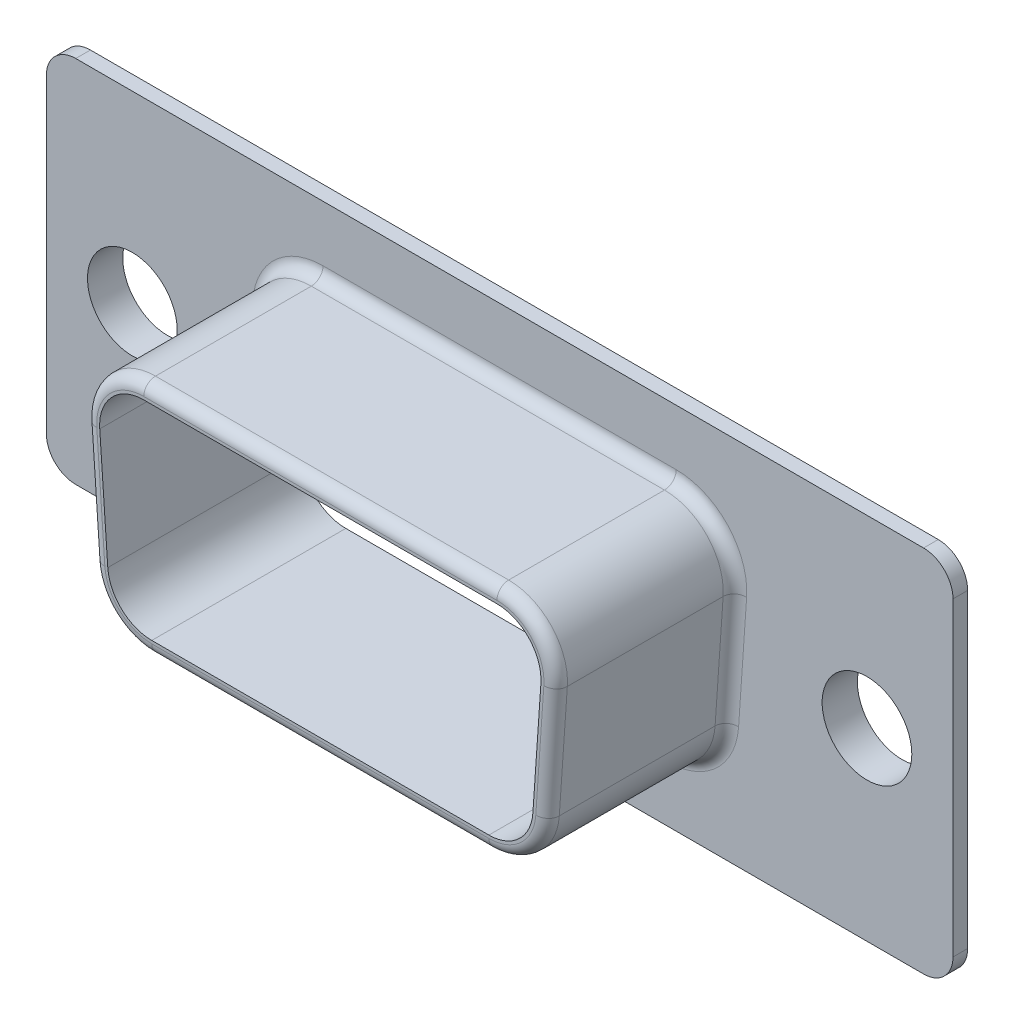
from build123d import *

# Parameters (mm, degrees)
BOSS_EXTRUDE1_DEPTH = 0.5
SKETCH2_R           = 1.525
CUT_EXTRUDE1_DEPTH  = 0.5
BOSS_EXTRUDE2_DEPTH = 6.1
SKETCH9_R           = 1.825
SKETCH9_R_2         = 1.525
BOSS_EXTRUDE3_DEPTH = 0.5
SKETCH10_R          = 2.025
SKETCH10_R_2        = 1.525
BOSS_EXTRUDE4_DEPTH = 0.2
CUT_EXTRUDE2_DEPTH  = 6.6
FILLET1_R           = 0.4
FILLET2_R           = 0.4


with BuildPart() as part:
    # Sketch1 → Boss-Extrude1 (new body)
    with BuildSketch(Plane.XY):
        with BuildLine():
            Line((-14.42, 6.275), (14.42, 6.275))
            ThreePointArc((14.42, 6.275), (15.127106781, 5.982106781), (15.42, 5.275))
            Line((15.42, 5.275), (15.42, -5.275))
            ThreePointArc((15.42, -5.275), (15.127106781, -5.982106781), (14.42, -6.275))
            Line((14.42, -6.275), (-14.42, -6.275))
            ThreePointArc((-14.42, -6.275), (-15.127106781, -5.982106781), (-15.42, -5.275))
            Line((-15.42, -5.275), (-15.42, 5.275))
            ThreePointArc((-15.42, 5.275), (-15.127106781, 5.982106781), (-14.42, 6.275))
        make_face()
    extrude(amount=BOSS_EXTRUDE1_DEPTH)

    # Sketch2 → Cut-Extrude1 (cut)
    with BuildSketch(Plane.XY.offset(0.5)):
        with Locations((-12.495, 0)):
            Circle(SKETCH2_R)
        with Locations((12.495, 0)):
            Circle(SKETCH2_R)
    extrude(amount=-CUT_EXTRUDE1_DEPTH, mode=Mode.SUBTRACT)

    # Sketch3 → Boss-Extrude2 (add)
    with BuildSketch(Plane.XY.offset(0.5)):
        with BuildLine():
            Line((-6.00685473, 3.975), (6.00685473, 3.975))
            ThreePointArc((6.00685473, 3.975), (7.469056783, 3.339538441), (8.00208564, 1.836965157))
            Line((8.00208564, 1.836965157), (7.7288152, -2.113034843))
            ThreePointArc((7.7288152, -2.113034843), (7.098122731, -3.437202053), (5.73358429, -3.975))
            Line((5.73358429, -3.975), (-5.73358429, -3.975))
            ThreePointArc((-5.73358429, -3.975), (-7.098122731, -3.437202053), (-7.7288152, -2.113034843))
            Line((-7.7288152, -2.113034843), (-8.00208564, 1.836965157))
            ThreePointArc((-8.00208564, 1.836965157), (-7.469056783, 3.339538441), (-6.00685473, 3.975))
        make_face()
    extrude(amount=BOSS_EXTRUDE2_DEPTH)

    # Sketch9 → Boss-Extrude3 (add)
    with BuildSketch(Plane(origin=(0, 0, 0), x_dir=(-1, 0, 0), z_dir=(0, 0, -1))):
        with Locations((-12.495, 0)):
            Circle(SKETCH9_R)
        with Locations(Location((-12.495, 0, 0), (0, 0, 180))):
            Circle(SKETCH9_R_2, mode=Mode.SUBTRACT)
        with Locations((12.495, 0)):
            Circle(SKETCH9_R)
        with Locations(Location((12.495, 0, 0), (0, 0, 180))):
            Circle(SKETCH9_R_2, mode=Mode.SUBTRACT)
    extrude(amount=BOSS_EXTRUDE3_DEPTH)

    # Sketch10 → Boss-Extrude4 (add)
    with BuildSketch(Plane(origin=(0, 0, -0.5), x_dir=(-1, 0, 0), z_dir=(0, 0, -1))):
        with Locations((-12.495, 0)):
            Circle(SKETCH10_R)
        with Locations(Location((-12.495, 0, 0), (0, 0, 180))):
            Circle(SKETCH10_R_2, mode=Mode.SUBTRACT)
        with Locations((12.495, 0)):
            Circle(SKETCH10_R)
        with Locations(Location((12.495, 0, 0), (0, 0, 180))):
            Circle(SKETCH10_R_2, mode=Mode.SUBTRACT)
    extrude(amount=BOSS_EXTRUDE4_DEPTH)

    # Sketch11 → Cut-Extrude2 (cut)
    with BuildSketch(Plane.XY.offset(6.6)):
        with BuildLine():
            Line((-7.503277912, 1.871473868), (-7.230007472, -2.078526132))
            ThreePointArc((-7.230007472, -2.078526132), (-6.756988121, -3.071651539), (-5.73358429, -3.475))
            Line((-5.73358429, -3.475), (5.73358429, -3.475))
            ThreePointArc((5.73358429, -3.475), (6.756988121, -3.071651539), (7.230007472, -2.078526132))
            Line((7.230007472, -2.078526132), (7.503277912, 1.871473868))
            ThreePointArc((7.503277912, 1.871473868), (7.10350627, 2.998403831), (6.00685473, 3.475))
            Line((6.00685473, 3.475), (-6.00685473, 3.475))
            ThreePointArc((-6.00685473, 3.475), (-7.10350627, 2.998403831), (-7.503277912, 1.871473868))
        make_face()
    extrude(amount=-CUT_EXTRUDE2_DEPTH, mode=Mode.SUBTRACT)

    # Fillet1
    fillet1_edges = [part.edges().sort_by_distance(p)[0] for p in [
        (7.098122731, -3.437202053, 6.6),
        (7.86545042, -0.138034843, 6.6),
        (7.469056783, 3.339538441, 6.6),
        (0, 3.975, 6.6),
        (-7.469056783, 3.339538441, 6.6),
        (-7.86545042, -0.138034843, 6.6),
        (-7.098122731, -3.437202053, 6.6),
        (0, -3.975, 6.6),
    ]]
    fillet(fillet1_edges, radius=FILLET1_R)

    # Fillet2
    fillet2_edges = [part.edges().sort_by_distance(p)[0] for p in [
        (7.098122731, -3.437202053, 0.5),
        (7.86545042, -0.138034843, 0.5),
        (7.469056783, 3.339538441, 0.5),
        (0, 3.975, 0.5),
        (-7.469056783, 3.339538441, 0.5),
        (-7.86545042, -0.138034843, 0.5),
        (-7.098122731, -3.437202053, 0.5),
        (0, -3.975, 0.5),
    ]]
    fillet(fillet2_edges, radius=FILLET2_R)


solid = part.part
